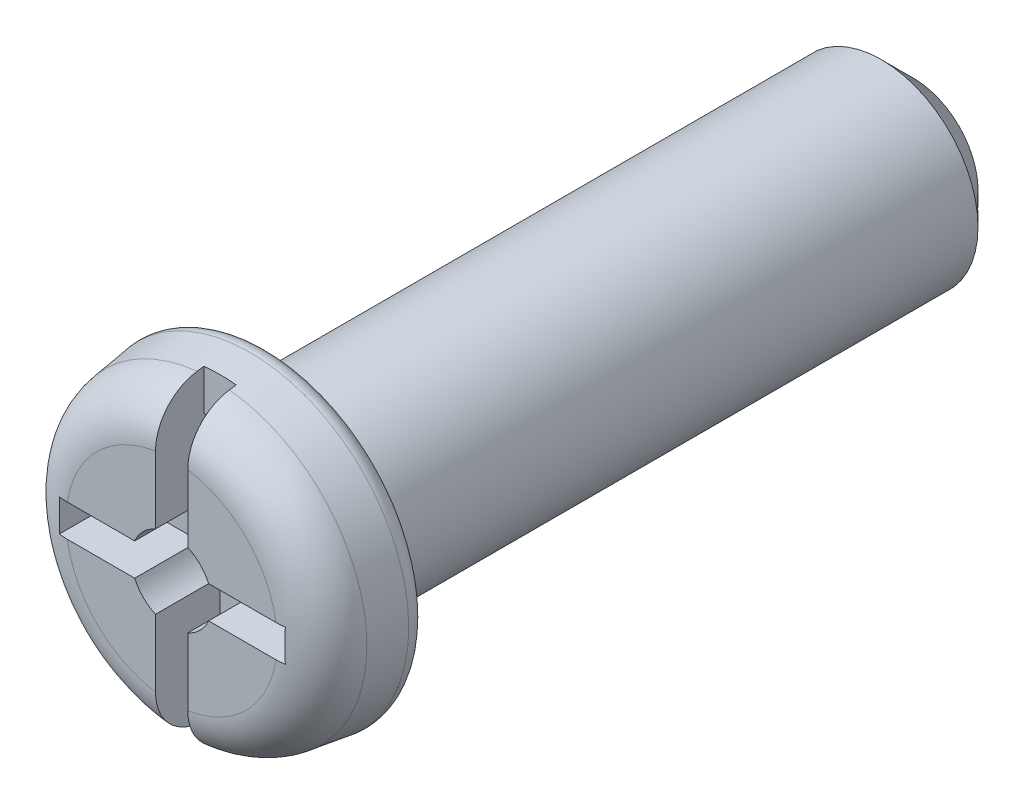
from build123d import *

# Parameters (mm, degrees)
ESQUISSE1_R             = 2.5
BASE_EXTRUSION_DEPTH    = 1.5
BASE_EXTRUSION_TAPER    = 8
CONG_1_R                = 0.75
CONG_2_R                = 0.25
ESQUISSE2_R             = 1.5
BOSS_EXTRU_1_DEPTH      = 10
CHANFREIN1_SIZE         = 0.5
ENL_V_MAT_EXTRU_1_DEPTH = 1
ESQUISSE5_W             = 0.5
ESQUISSE5_H             = 5.000243794
ENL_V_MAT_EXTRU_2_DEPTH = 0.75


with BuildPart() as part:
    # Esquisse1 → Base-Extrusion (new body)
    with BuildSketch(Plane.XY):
        Circle(ESQUISSE1_R)
    extrude(amount=BASE_EXTRUSION_DEPTH, taper=BASE_EXTRUSION_TAPER)

    # Congé1
    cong_1_edges = [part.edges().sort_by_distance(p)[0] for p in [
        (-2.289188748, 0, 1.5),
    ]]
    fillet(cong_1_edges, radius=CONG_1_R)

    # Congé2
    cong_2_edges = [part.edges().sort_by_distance(p)[0] for p in [
        (-2.5, 0, 0),
    ]]
    fillet(cong_2_edges, radius=CONG_2_R)

    # Esquisse2 → Boss.-Extru.1 (add)
    with BuildSketch(Plane(origin=(0, 0, 0), x_dir=(-1, 0, 0), z_dir=(0, 0, -1))):
        Circle(ESQUISSE2_R)
    extrude(amount=BOSS_EXTRU_1_DEPTH)

    # Chanfrein1
    chanfrein1_edges = [part.edges().sort_by_distance(p)[0] for p in [
        (1.5, 0, -10),
    ]]
    chamfer(chanfrein1_edges, length=CHANFREIN1_SIZE)

    # Esquisse4 → Enlèv. mat.-Extru.1 (cut)
    with BuildSketch(Plane.XY.offset(1.5)):
        with BuildLine():
            Line((-0.25, 1.75), (-0.25, 0.572821962))
            ThreePointArc((-0.25, 0.572821962), (-0.441941738, 0.441941738), (-0.572821962, 0.25))
            Line((-0.572821962, 0.25), (-1.75, 0.25))
            Line((-1.75, 0.25), (-1.75, -0.25))
            Line((-1.75, -0.25), (-0.572821962, -0.25))
            ThreePointArc((-0.572821962, -0.25), (-0.441941738, -0.441941738), (-0.25, -0.572821962))
            Line((-0.25, -0.572821962), (-0.25, -1.75))
            Line((-0.25, -1.75), (0.25, -1.75))
            Line((0.25, -1.75), (0.25, -0.572821962))
            ThreePointArc((0.25, -0.572821962), (0.441941738, -0.441941738), (0.572821962, -0.25))
            Line((0.572821962, -0.25), (1.75, -0.25))
            Line((1.75, -0.25), (1.75, 0.25))
            Line((1.75, 0.25), (0.572821962, 0.25))
            ThreePointArc((0.572821962, 0.25), (0.441941738, 0.441941738), (0.25, 0.572821962))
            Line((0.25, 0.572821962), (0.25, 1.75))
            Line((0.25, 1.75), (-0.25, 1.75))
        make_face()
    extrude(amount=-ENL_V_MAT_EXTRU_1_DEPTH, mode=Mode.SUBTRACT)

    # Esquisse5 → Enlèv. mat.-Extru.2 (cut)
    with BuildSketch(Plane.XY.offset(1.5)):
        with Locations((0, 0.01124212)):
            Rectangle(ESQUISSE5_W, ESQUISSE5_H)
    extrude(amount=-ENL_V_MAT_EXTRU_2_DEPTH, mode=Mode.SUBTRACT)


solid = part.part
